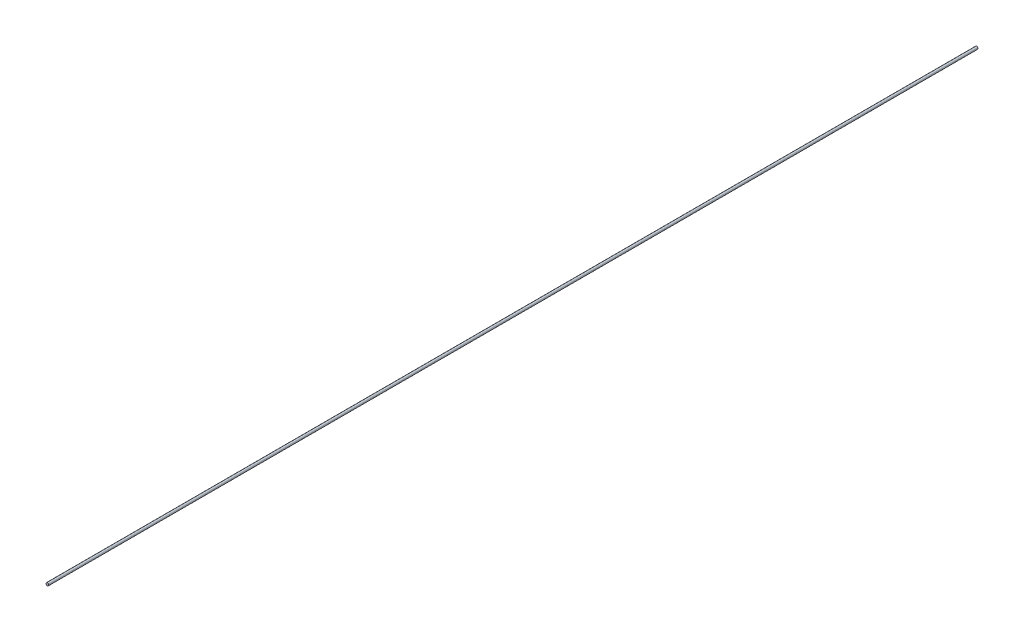
from build123d import *

# Parameters (mm, degrees)
SKETCH1_R           = 1
BOSS_EXTRUDE1_DEPTH = 700


with BuildPart() as part:
    # Sketch1 → Boss-Extrude1 (new body)
    with BuildSketch(Plane.XY):
        Circle(SKETCH1_R)
    extrude(amount=BOSS_EXTRUDE1_DEPTH)


solid = part.part
